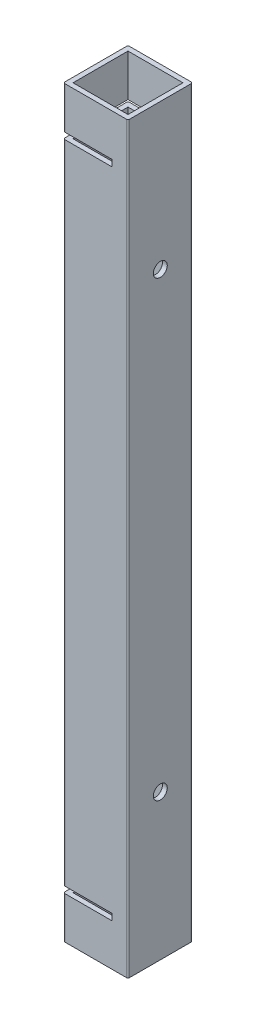
from build123d import *

# Parameters (mm, degrees)
SKETCH1_W           = 17
SKETCH1_H           = 17
BOSS_EXTRUDE1_DEPTH = 230
SKETCH2_W           = 20
SKETCH2_H           = 2
CUT_EXTRUDE1_DEPTH  = 15
SKETCH3_R           = 2.15
CUT_EXTRUDE2_DEPTH  = 232.732604525


with BuildPart() as part:
    # Sketch1 → Boss-Extrude1 (new body)
    with BuildSketch(Plane(origin=(0, 0, 0), x_dir=(1, 0, 0), z_dir=(0, 1, 0))):
        with BuildLine():
            Line((0.5, 0), (19.5, 0))
            ThreePointArc((19.5, 0), (19.853553391, 0.146446609), (20, 0.5))
            Line((20, 0.5), (20, 19.5))
            ThreePointArc((20, 19.5), (19.853553391, 19.853553391), (19.5, 20))
            Line((19.5, 20), (0.5, 20))
            ThreePointArc((0.5, 20), (0.146446609, 19.853553391), (0, 19.5))
            Line((0, 19.5), (0, 0.5))
            ThreePointArc((0, 0.5), (0.146446609, 0.146446609), (0.5, 0))
        make_face()
        with Locations((10, 10)):
            Rectangle(SKETCH1_W, SKETCH1_H, mode=Mode.SUBTRACT)
    extrude(amount=BOSS_EXTRUDE1_DEPTH)

    # Sketch2 → Cut-Extrude1 (cut)
    with BuildSketch(Plane.ZY):
        with Locations((-10, 14)):
            Rectangle(SKETCH2_W, SKETCH2_H)
        with Locations((-10, 216)):
            Rectangle(SKETCH2_W, SKETCH2_H)
    extrude(amount=-CUT_EXTRUDE1_DEPTH, mode=Mode.SUBTRACT)

    # Sketch3 → Cut-Extrude2 (cut, through all)
    with BuildSketch(Plane(origin=(20, 0, 0), x_dir=(0, 0, -1), z_dir=(1, 0, 0))):
        with Locations((10, 185)):
            Circle(SKETCH3_R)
        with Locations(Location((10, 45, 0), (0, 0, 180))):
            Circle(SKETCH3_R)
    extrude(amount=-CUT_EXTRUDE2_DEPTH, mode=Mode.SUBTRACT)


solid = part.part
